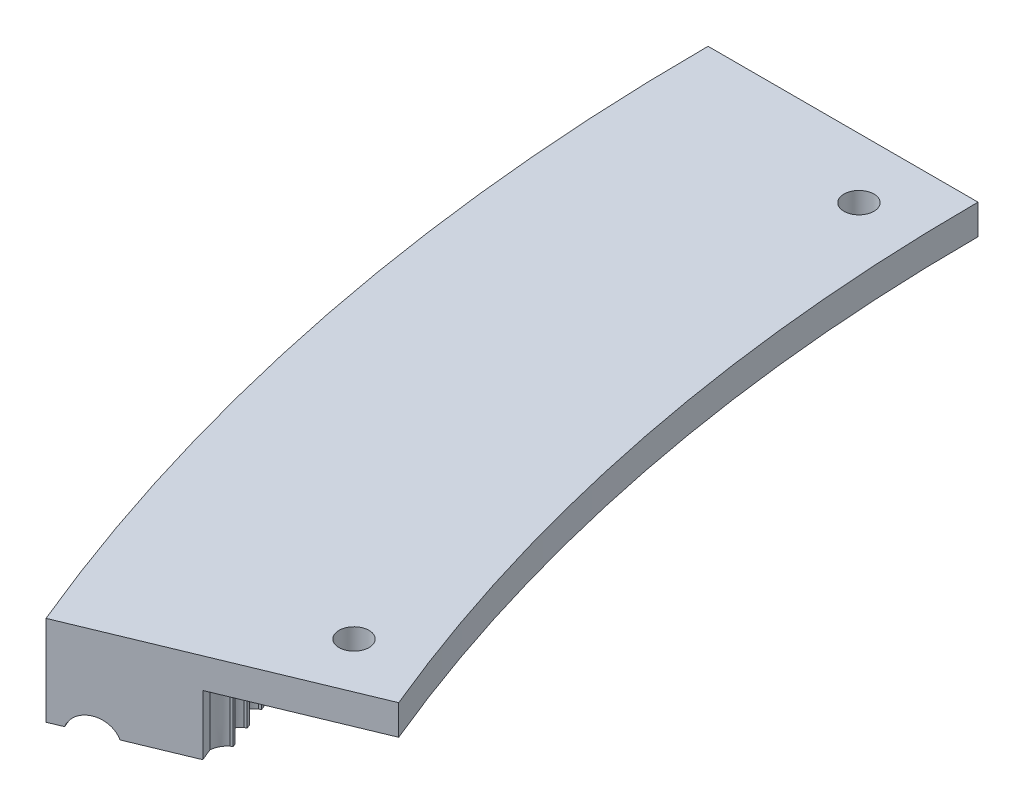
from build123d import *

# Parameters (mm, degrees)
REVOLVE1_ANGLE      = 22.5
SKETCH7_R           = 3.175
CUT_EXTRUDE1_DEPTH  = 7.35
BOSS_EXTRUDE1_DEPTH = 12.7
CIRPATTERN1_COUNT   = 32
CIRPATTERN1_ANGLE   = 21.8


with BuildPart() as part:
    # Sketch3 → Revolve1 (revolve)
    with BuildSketch(Plane.XY):
        with BuildLine():
            Line((-400.05, 0), (-457.2, 0))
            Line((-457.2, 0), (-457.2, -19.05))
            Line((-457.2, -19.05), (-454.191739556, -19.05))
            ThreePointArc((-454.191739556, -19.05), (-449.701611496, -15.875), (-445.211483435, -19.05))
            Line((-445.211483435, -19.05), (-431.8, -19.05))
            Line((-431.8, -19.05), (-431.8, -6.35))
            Line((-431.8, -6.35), (-425.45, -6.35))
            Line((-425.45, -6.35), (-400.05, -6.35))
            Line((-400.05, -6.35), (-400.05, 0))
        make_face()
    revolve(axis=Axis((0, 0, 0), (0, 1, 0)), revolution_arc=REVOLVE1_ANGLE)

    # Sketch7 → Cut-Extrude1 (cut, through all)
    with BuildSketch(Plane.XZ.offset(6.35)):
        with Locations((-412.554569118, 12.7)):
            Circle(SKETCH7_R)
        with Locations((-386.010802043, 146.144528485)):
            Circle(SKETCH7_R)
    extrude(amount=-CUT_EXTRUDE1_DEPTH, mode=Mode.SUBTRACT)

    # Sketch10 → Boss-Extrude1 (add)
    with BuildSketch(Plane.XZ.offset(6.35)):
        with BuildLine():
            Line((-429.439717222, -0.4637294), (-428.926837997, -0.436850539))
            ThreePointArc((-428.926837997, -0.436850539), (-428.928345872, -0.022684362), (-428.905164129, 0.39083529))
            Line((-428.905164129, 0.39083529), (-429.41593372, 0.444519526))
            add(Edge.make_bspline(
                [(-431.843612442, 2.60285791), (-431.276447881, 1.501039829), (-430.46684712, 0.781592928), (-429.41593372, 0.444519526)],
                knots=[0.069617967, 0.069617967, 0.069617967, 0.069617967, 1, 1, 1, 1], degree=3))
            ThreePointArc((-431.843612442, 2.60285791), (-431.851426092, 0.162044966), (-431.845444192, -2.278773155))
            add(Edge.make_bspline(
                [(-431.845444192, -2.278773155), (-431.235764751, -1.331097182), (-430.434269231, -0.726176885), (-429.439717222, -0.4637294)],
                knots=[0.132959125, 0.132959125, 0.132959125, 0.132959125, 1, 1, 1, 1], degree=3))
        make_face()
    boss_extrude1 = extrude(amount=BOSS_EXTRUDE1_DEPTH)

    # CirPattern1: Boss-Extrude1 ×32 about axis
    cirpattern1_axis = Axis((0, 0, 0), (0, 1, 0))
    for i in range(1, CIRPATTERN1_COUNT):
        add(boss_extrude1.rotate(cirpattern1_axis, i * CIRPATTERN1_ANGLE / (CIRPATTERN1_COUNT - 1)))


solid = part.part
